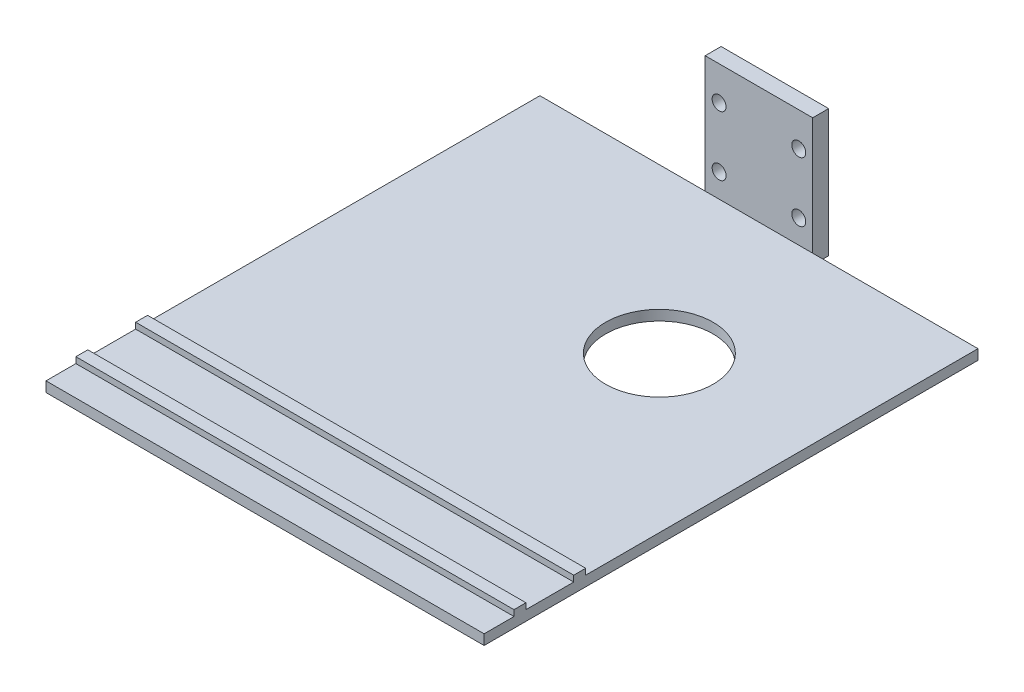
from build123d import *

# Parameters (mm, degrees)
SCHIZZO1_W                        = 27
SCHIZZO1_H                        = 36
ESTRUSIONE_ESTRUSIONE1_DEPTH      = 4
SCHIZZO10_R                       = 1.75
TAGLIO_ESTRUSIONE5_DEPTH          = 10
SCHIZZO12_W                       = 124
SCHIZZO12_H                       = 2.549259356
ESTRUSIONE_ESTRUSIONE2_DEPTH      = 55
ESTRUSIONE_ESTRUSIONE2_DEPTH_BACK = 55
SCHIZZO14_W                       = 3
SCHIZZO14_H                       = 1.5
ESTRUSIONE_ESTRUSIONE3_DEPTH      = 110
SCHIZZO15_W                       = 27
SCHIZZO15_H                       = 4
TAGLIO_ESTRUSIONE6_DEPTH          = 5
SCHIZZO16_R                       = 13.5
TAGLIO_ESTRUSIONE7_DEPTH          = 10


with BuildPart() as part:
    # Schizzo1 → Estrusione-Estrusione1 (new body)
    with BuildSketch(Plane.XY):
        with Locations((13.5, -18)):
            Rectangle(SCHIZZO1_W, SCHIZZO1_H)
    extrude(amount=ESTRUSIONE_ESTRUSIONE1_DEPTH)

    # Schizzo10 → Taglio-Estrusione5 (cut)
    with BuildSketch(Plane.XY.offset(4)):
        with Locations((3.5, -12.5)):
            Circle(SCHIZZO10_R)
        with Locations((23.5, -12.5)):
            Circle(SCHIZZO10_R)
        with Locations((23.5, -27.5)):
            Circle(SCHIZZO10_R)
        with Locations((3.5, -27.5)):
            Circle(SCHIZZO10_R)
    extrude(amount=-TAGLIO_ESTRUSIONE5_DEPTH, mode=Mode.SUBTRACT)

    # Schizzo12 → Estrusione-Estrusione2 (add, two sides)
    with BuildSketch(Plane(origin=(13.5, 0, 0), x_dir=(0, 0, -1), z_dir=(1, 0, 0))) as estrusione_estrusione2_sk:
        with Locations((-66, -34.725370322)):
            Rectangle(SCHIZZO12_W, SCHIZZO12_H)
    extrude(amount=ESTRUSIONE_ESTRUSIONE2_DEPTH)
    extrude(estrusione_estrusione2_sk.sketch, amount=-ESTRUSIONE_ESTRUSIONE2_DEPTH_BACK)

    # Schizzo14 → Estrusione-Estrusione3 (add)
    with BuildSketch(Plane.ZY.offset(41.5)):
        with Locations((104, -32.700740644)):
            Rectangle(SCHIZZO14_W, SCHIZZO14_H)
        with Locations((119, -32.700740644)):
            Rectangle(SCHIZZO14_W, SCHIZZO14_H)
    extrude(amount=-ESTRUSIONE_ESTRUSIONE3_DEPTH)

    # Schizzo15 → Taglio-Estrusione6 (cut, through all)
    with BuildSketch(Plane.XY.offset(4)):
        with Locations((13.5, -2)):
            Rectangle(SCHIZZO15_W, SCHIZZO15_H)
    extrude(amount=-TAGLIO_ESTRUSIONE6_DEPTH, mode=Mode.SUBTRACT)

    # Schizzo16 → Taglio-Estrusione7 (cut)
    with BuildSketch(Plane(origin=(0, -33.450740644, 0), x_dir=(1, 0, 0), z_dir=(0, 1, 0))):
        with Locations((29.5, -45)):
            Circle(SCHIZZO16_R)
    extrude(amount=-TAGLIO_ESTRUSIONE7_DEPTH, mode=Mode.SUBTRACT)


solid = part.part
